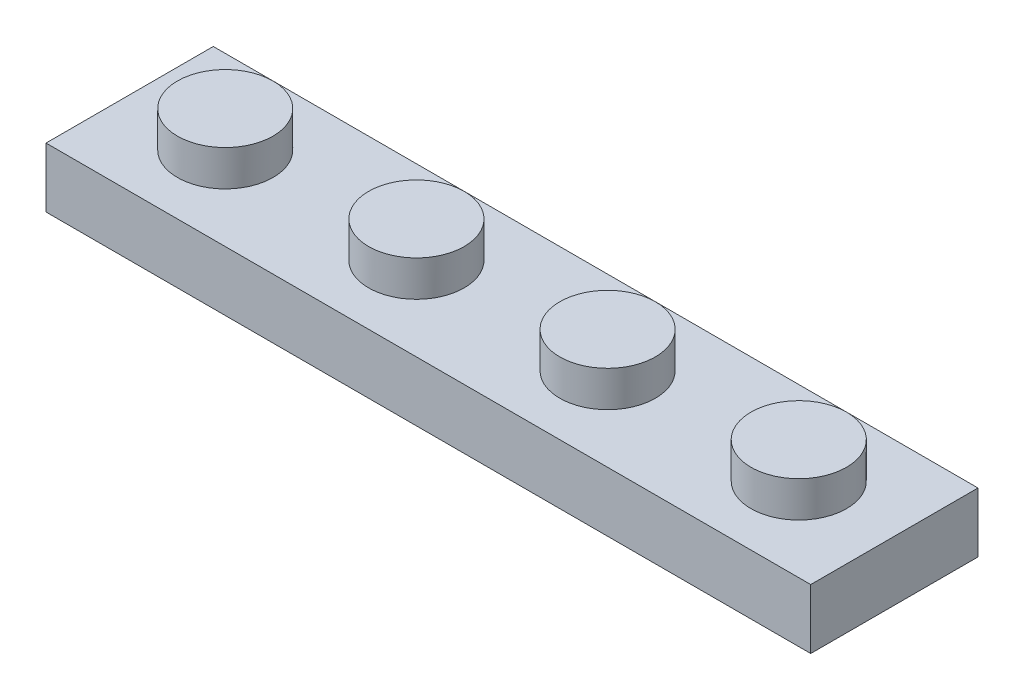
from build123d import *

# Parameters (mm, degrees)
SKETCH1_W           = 40.64
SKETCH1_H           = 3.175
BOSS_EXTRUDE1_DEPTH = 4.445
SKETCH2_R           = 2.54
BOSS_EXTRUDE2_DEPTH = 1.905
SKETCH3_W           = 38.1
SKETCH3_H           = 5.08
CUT_EXTRUDE1_DEPTH  = 1.905
SKETCH4_R           = 1.905
CUT_EXTRUDE2_DEPTH  = 2.54
SKETCH5_R           = 1.905
SKETCH5_R_2         = 0.9525
BOSS_EXTRUDE3_DEPTH = 1.905


with BuildPart() as part:
    # Sketch1 → Boss-Extrude1 (new body, symmetric)
    with BuildSketch(Plane.XY):
        with Locations((0, -1.5875)):
            Rectangle(SKETCH1_W, SKETCH1_H)
    extrude(amount=BOSS_EXTRUDE1_DEPTH, both=True)

    # Sketch2 → Boss-Extrude2 (add)
    with BuildSketch(Plane(origin=(0, 0, 0), x_dir=(1, 0, 0), z_dir=(0, 1, 0))):
        with Locations((-15.24, 0)):
            Circle(SKETCH2_R)
        with Locations((-5.08, 0)):
            Circle(SKETCH2_R)
        with Locations((5.08, 0)):
            Circle(SKETCH2_R)
        with Locations((15.24, 0)):
            Circle(SKETCH2_R)
    extrude(amount=BOSS_EXTRUDE2_DEPTH)

    # Sketch3 → Cut-Extrude1 (cut)
    with BuildSketch(Plane.XZ.offset(3.175)):
        Rectangle(SKETCH3_W, SKETCH3_H)
    extrude(amount=-CUT_EXTRUDE1_DEPTH, mode=Mode.SUBTRACT)

    # Sketch4 → Cut-Extrude2 (cut)
    with BuildSketch(Plane.XZ.offset(1.27)):
        with Locations((-15.24, 0)):
            Circle(SKETCH4_R)
        with Locations((-5.08, 0)):
            Circle(SKETCH4_R)
        with Locations((5.08, 0)):
            Circle(SKETCH4_R)
        with Locations((15.24, 0)):
            Circle(SKETCH4_R)
    extrude(amount=-CUT_EXTRUDE2_DEPTH, mode=Mode.SUBTRACT)

    # Sketch5 → Boss-Extrude3 (add)
    with BuildSketch(Plane.XZ.offset(1.27)):
        with Locations((-10.16, 0)):
            Circle(SKETCH5_R)
        with Locations((-10.16, 0)):
            Circle(SKETCH5_R_2, mode=Mode.SUBTRACT)
        with Locations((10.16, 0)):
            Circle(SKETCH5_R)
        with Locations((10.16, 0)):
            Circle(SKETCH5_R_2, mode=Mode.SUBTRACT)
        Circle(SKETCH5_R)
        Circle(SKETCH5_R_2, mode=Mode.SUBTRACT)
    extrude(amount=BOSS_EXTRUDE3_DEPTH)


solid = part.part
